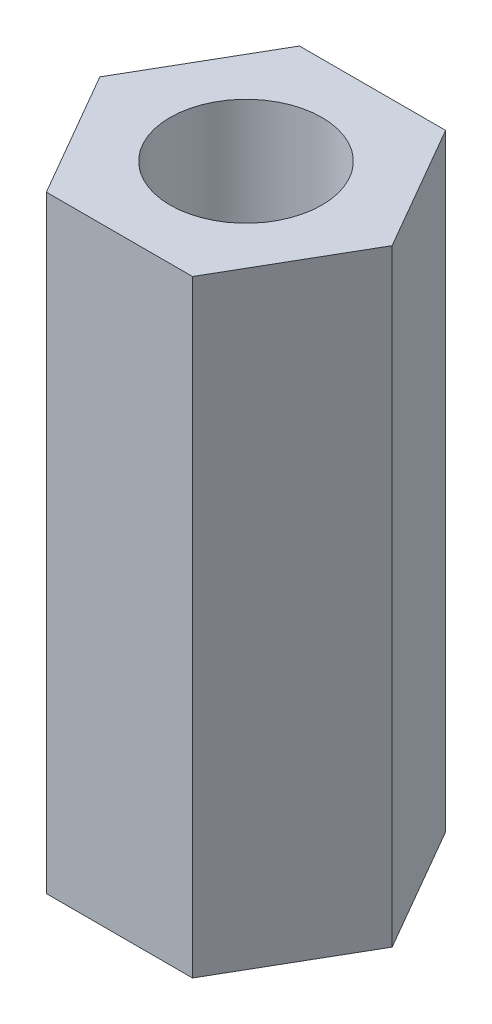
from build123d import *

# Parameters (mm, degrees)
CROQUIS1_R              = 1.5
SALIENTE_EXTRUIR1_DEPTH = 6


with BuildPart() as part:
    # Croquis1 → Saliente-Extruir1 (new body, symmetric)
    with BuildSketch(Plane(origin=(0, 0, 0), x_dir=(1, 0, 0), z_dir=(0, 1, 0))):
        Polygon((1.443375673, -2.5), (2.886751346, 0), (1.443375673, 2.5), (-1.443375673, 2.5), (-2.886751346, 0), (-1.443375673, -2.5), align=None)
        Circle(CROQUIS1_R, mode=Mode.SUBTRACT)
    extrude(amount=SALIENTE_EXTRUIR1_DEPTH, both=True)


solid = part.part
